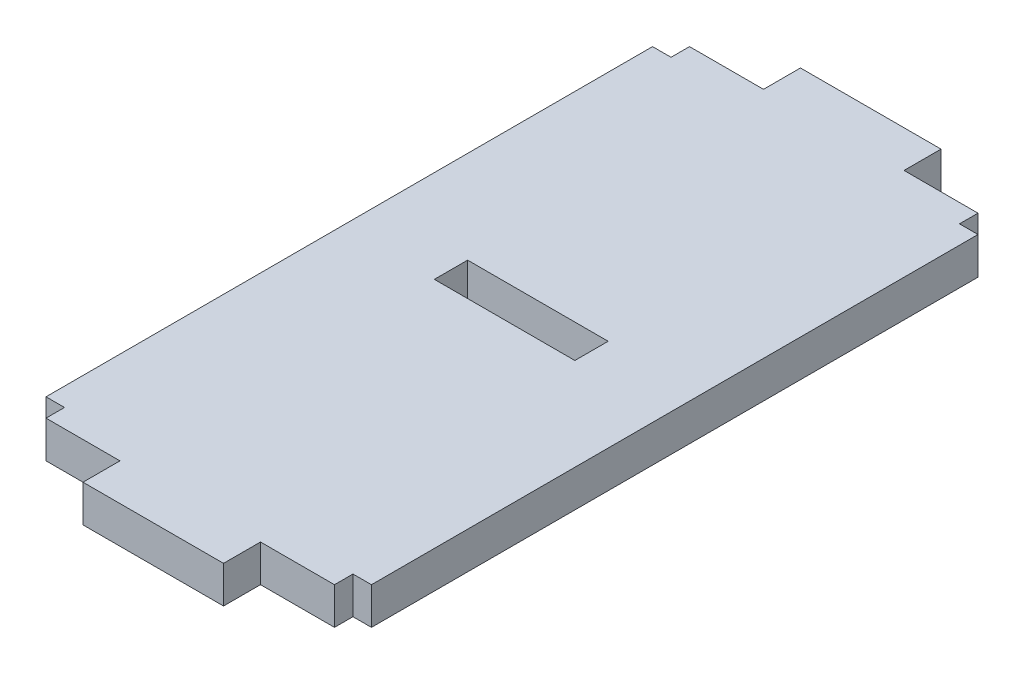
from build123d import *

# Parameters (mm, degrees)
SKETCH_1_W      = 7.6
SKETCH_1_H      = 1.8
EXTRUDE_1_DEPTH = 2


with BuildPart() as part:
    # 草图1 → 凸台-拉伸1 (new body)
    with BuildSketch(Plane(origin=(0, 0, 0), x_dir=(1, 0, 0), z_dir=(0, 1, 0))):
        Polygon((1, 1), (1, 0), (5, 0), (5, -2), (12.6, -2), (12.6, 0), (16.6, 0), (16.6, 1), (17.6, 1), (17.6, 33.8), (16.6, 33.8), (16.6, 34.8), (12.6, 34.8), (12.6, 36.8), (5, 36.8), (5, 34.8), (1, 34.8), (1, 33.8), (0, 33.8), (0, 1), align=None)
        with Locations((8.8, 17.9)):
            Rectangle(SKETCH_1_W, SKETCH_1_H, mode=Mode.SUBTRACT)
    extrude(amount=EXTRUDE_1_DEPTH)


solid = part.part
